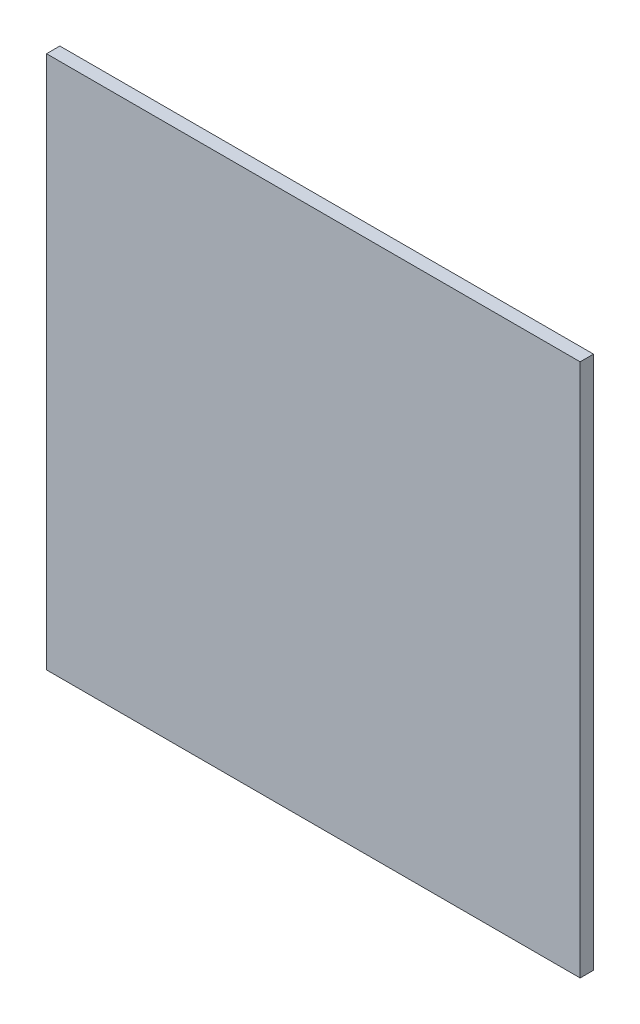
from build123d import *

# Parameters (mm, degrees)
SKETCH1_W           = 0.4
SKETCH1_H           = 0.4
BOSS_EXTRUDE1_DEPTH = 0.01


with BuildPart() as part:
    # Sketch1 → Boss-Extrude1 (new body)
    with BuildSketch(Plane.XY):
        Rectangle(SKETCH1_W, SKETCH1_H)
    extrude(amount=BOSS_EXTRUDE1_DEPTH)


solid = part.part
